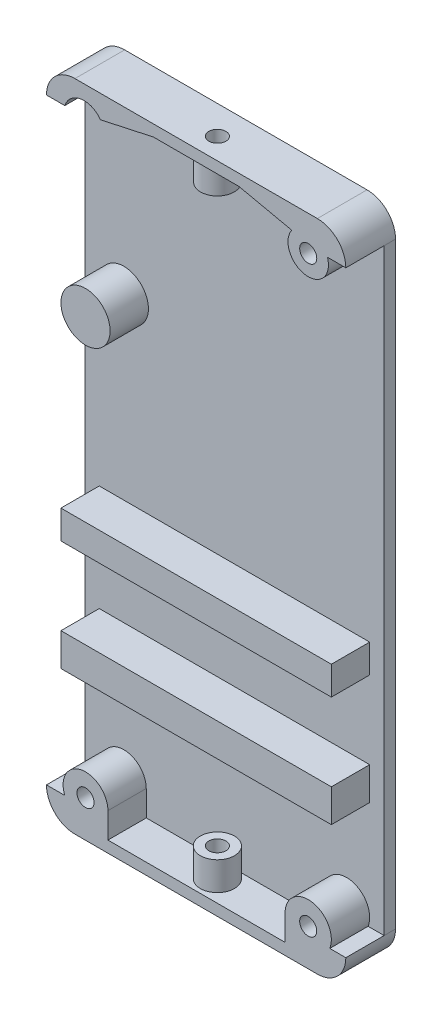
from build123d import *

# Parameters (mm, degrees)
BOSS_EXTRUDE1_DEPTH = 2
SKETCH2_R           = 3.556
SKETCH2_R_2         = 1.5
SKETCH2_R_3         = 4.318
SKETCH2_R_4         = 4.064
SKETCH2_R_5         = 3.937
SKETCH2_W           = 47.498
SKETCH2_H           = 5.002835781
SKETCH2_H_2         = 5.760841202
BOSS_EXTRUDE2_DEPTH = 6.732423
BOSS_EXTRUDE3_DEPTH = 6.732423
SKETCH4_R           = 1.5
CUT_EXTRUDE1_DEPTH  = 10
SKETCH5_R           = 1.5
CUT_EXTRUDE2_DEPTH  = 10
SKETCH6_R           = 2.95
SKETCH6_R_2         = 1.5
BOSS_EXTRUDE5_DEPTH = 5
SKETCH7_R           = 2.995
SKETCH7_R_2         = 1.5
BOSS_EXTRUDE6_DEPTH = 5


with BuildPart() as part:
    # Sketch1 → Boss-Extrude1 (new body)
    with BuildSketch(Plane.XY.offset(-28.86000007)):
        with BuildLine():
            Line((-10.615664433, 166.948874967), (-10.615664433, 62.013874967))
            ThreePointArc((-10.615664433, 62.013874967), (-12.080130527, 58.478341061), (-15.615664433, 57.013874967))
            Line((-15.615664433, 57.013874967), (-58.193664433, 57.013874967))
            ThreePointArc((-58.193664433, 57.013874967), (-61.729198339, 58.478341061), (-63.193664433, 62.013874967))
            Line((-63.193664433, 62.013874967), (-63.193664433, 166.948874967))
            ThreePointArc((-63.193664433, 166.948874967), (-61.729198339, 170.484408873), (-58.193664433, 171.948874967))
            Line((-58.193664433, 171.948874967), (-15.615664433, 171.948874967))
            ThreePointArc((-15.615664433, 171.948874967), (-12.080130527, 170.484408873), (-10.615664433, 166.948874967))
        make_face()
    extrude(amount=-BOSS_EXTRUDE1_DEPTH)

    # Sketch2 → Boss-Extrude2 (add)
    with BuildSketch(Plane.XY.offset(-28.86000007)):
        with Locations((-17.219664433, 165.852874967)):
            Circle(SKETCH2_R)
        with Locations((-17.219664433, 165.852874967)):
            Circle(SKETCH2_R_2, mode=Mode.SUBTRACT)
        with Locations((-56.335664433, 136.642874967)):
            Circle(SKETCH2_R_3)
        with Locations((-17.219664433, 63.490874967)):
            Circle(SKETCH2_R_4)
        with Locations((-17.219664433, 63.490874967)):
            Circle(SKETCH2_R_2, mode=Mode.SUBTRACT)
        with Locations((-56.335664433, 63.490874967)):
            Circle(SKETCH2_R_5)
        with Locations((-56.335664433, 63.490874967)):
            Circle(SKETCH2_R_2, mode=Mode.SUBTRACT)
        with Locations((-36.904664433, 102.883892021)):
            Rectangle(SKETCH2_W, SKETCH2_H)
        with Locations((-36.904664433, 83.857955944)):
            Rectangle(SKETCH2_W, SKETCH2_H_2)
    extrude(amount=BOSS_EXTRUDE2_DEPTH)

    # Sketch3 → Boss-Extrude3 (add)
    with BuildSketch(Plane.XY.offset(-28.86000007)):
        with BuildLine():
            Line((-29.404664433, 169.948874967), (-44.404664433, 169.948874967))
            Line((-44.404664433, 169.948874967), (-53.70076371, 167.92637168))
            ThreePointArc((-53.70076371, 167.92637168), (-57.137277803, 169.366456558), (-59.972550774, 166.948874967))
            Line((-59.972550774, 166.948874967), (-61.193664433, 166.948874967))
            Line((-61.193664433, 166.948874967), (-63.193664433, 166.948874967))
            ThreePointArc((-63.193664433, 166.948874967), (-61.729198339, 170.484408873), (-58.193664433, 171.948874967))
            Line((-58.193664433, 171.948874967), (-44.404664433, 171.948874967))
            Line((-44.404664433, 171.948874967), (-29.404664433, 171.948874967))
            Line((-29.404664433, 171.948874967), (-15.615664433, 171.948874967))
            ThreePointArc((-15.615664433, 171.948874967), (-12.080130527, 170.484408873), (-10.615664433, 166.948874967))
            Line((-10.615664433, 166.948874967), (-12.615664433, 166.948874967))
            Line((-12.615664433, 166.948874967), (-13.836778091, 166.948874967))
            ThreePointArc((-13.836778091, 166.948874967), (-16.672051062, 169.366456558), (-20.108565155, 167.92637168))
            Line((-20.108565155, 167.92637168), (-29.404664433, 169.948874967))
        make_face()
        with BuildLine():
            Line((-58.193664433, 57.013874967), (-15.615664433, 57.013874967))
            ThreePointArc((-15.615664433, 57.013874967), (-12.080130527, 58.478341061), (-10.615664433, 62.013874967))
            Line((-10.615664433, 62.013874967), (-12.615664433, 62.013874967))
            Line((-12.615664433, 62.013874967), (-13.433562612, 62.013874967))
            ThreePointArc((-13.433562612, 62.013874967), (-17.971122415, 59.496953723), (-21.283664433, 63.490874967))
            Line((-21.283664433, 63.490874967), (-21.283664433, 59.013874967))
            Line((-21.283664433, 59.013874967), (-52.398664433, 59.013874967))
            Line((-52.398664433, 59.013874967), (-52.398664433, 63.490874967))
            ThreePointArc((-52.398664433, 63.490874967), (-55.583298569, 59.626432626), (-59.985108226, 62.013874967))
            Line((-59.985108226, 62.013874967), (-61.193664433, 62.013874967))
            Line((-61.193664433, 62.013874967), (-63.193664433, 62.013874967))
            ThreePointArc((-63.193664433, 62.013874967), (-61.729198339, 58.478341061), (-58.193664433, 57.013874967))
        make_face()
    extrude(amount=BOSS_EXTRUDE3_DEPTH)

    # Sketch4 → Cut-Extrude1 (cut)
    with BuildSketch(Plane.XZ.offset(-57.013874967)):
        with Locations((-36.904664433, -25.86000007)):
            Circle(SKETCH4_R)
    extrude(amount=-CUT_EXTRUDE1_DEPTH, mode=Mode.SUBTRACT)

    # Sketch5 → Cut-Extrude2 (cut)
    with BuildSketch(Plane(origin=(0, 171.948874967, 0), x_dir=(1, 0, 0), z_dir=(0, 1, 0))):
        with Locations((-36.904664433, 25.86000007)):
            Circle(SKETCH5_R)
    extrude(amount=-CUT_EXTRUDE2_DEPTH, mode=Mode.SUBTRACT)

    # Sketch6 → Boss-Extrude5 (add)
    with BuildSketch(Plane.XZ.offset(-169.948874967)):
        with Locations((-36.904664433, -25.86000007)):
            Circle(SKETCH6_R)
        with Locations((-36.904664433, -25.86000007)):
            Circle(SKETCH6_R_2, mode=Mode.SUBTRACT)
    extrude(amount=BOSS_EXTRUDE5_DEPTH)

    # Sketch7 → Boss-Extrude6 (add)
    with BuildSketch(Plane(origin=(0, 59.013874967, 0), x_dir=(1, 0, 0), z_dir=(0, 1, 0))):
        with Locations((-36.904664433, 25.86000007)):
            Circle(SKETCH7_R)
        with Locations((-36.904664433, 25.86000007)):
            Circle(SKETCH7_R_2, mode=Mode.SUBTRACT)
    extrude(amount=BOSS_EXTRUDE6_DEPTH)


solid = part.part
